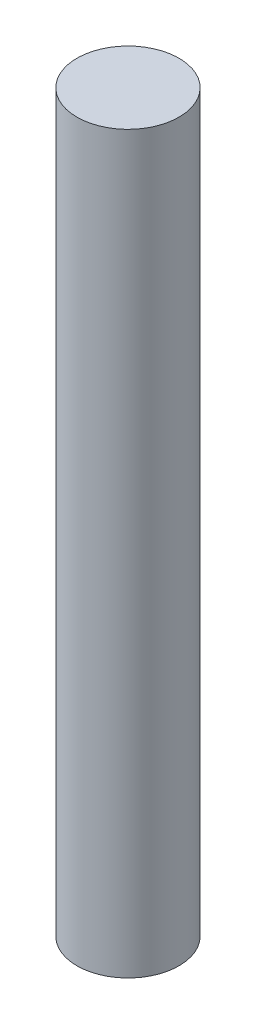
from build123d import *

# Parameters (mm, degrees)
SKETCH1_R           = 12.5
BOSS_EXTRUDE1_DEPTH = 90


with BuildPart() as part:
    # Sketch1 → Boss-Extrude1 (new body, symmetric)
    with BuildSketch(Plane(origin=(0, 0, 0), x_dir=(1, 0, 0), z_dir=(0, 1, 0))):
        Circle(SKETCH1_R)
    extrude(amount=BOSS_EXTRUDE1_DEPTH, both=True)


solid = part.part
